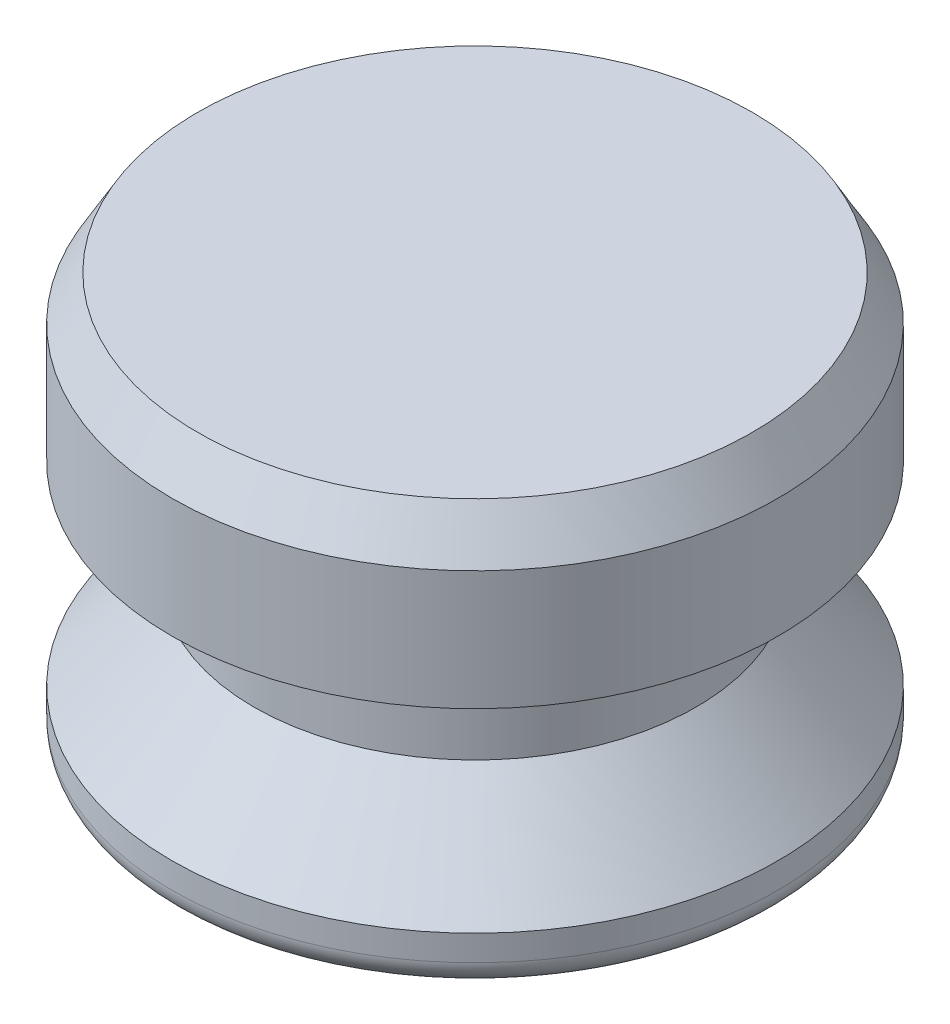
from build123d import *

# Parameters (mm, degrees)
FILLET1_R      = 0.79375
CHAMFER1_SIZE  = 0.79375
CHAMFER1_SIZE2 = 1.374815329


with BuildPart() as part:
    # Sketch1 → Revolve1 (revolve)
    with BuildSketch(Plane.XY):
        Polygon((0, 0), (-9.398, 0), (-9.398, 1.5875), (-6.858, 4.445), (-6.858, 7.62), (-9.398, 7.62), (-9.398, 12.7), (0, 12.7), align=None)
    revolve(axis=Axis((0, 0, 0), (0, 1, 0)))

    # Fillet1
    fillet1_edges = [part.edges().sort_by_distance(p)[0] for p in [
        (9.398, 0, 0),
    ]]
    fillet(fillet1_edges, radius=FILLET1_R)

    # Chamfer1
    chamfer1_edges = [part.edges().sort_by_distance(p)[0] for p in [
        (9.398, 12.7, 0),
    ]]
    chamfer1_side = [part.faces().sort_by_distance(p)[0] for p in [
        (0, 12.7, 0),
    ]]
    chamfer(chamfer1_edges, length=CHAMFER1_SIZE, length2=CHAMFER1_SIZE2, reference=chamfer1_side[0])


solid = part.part
